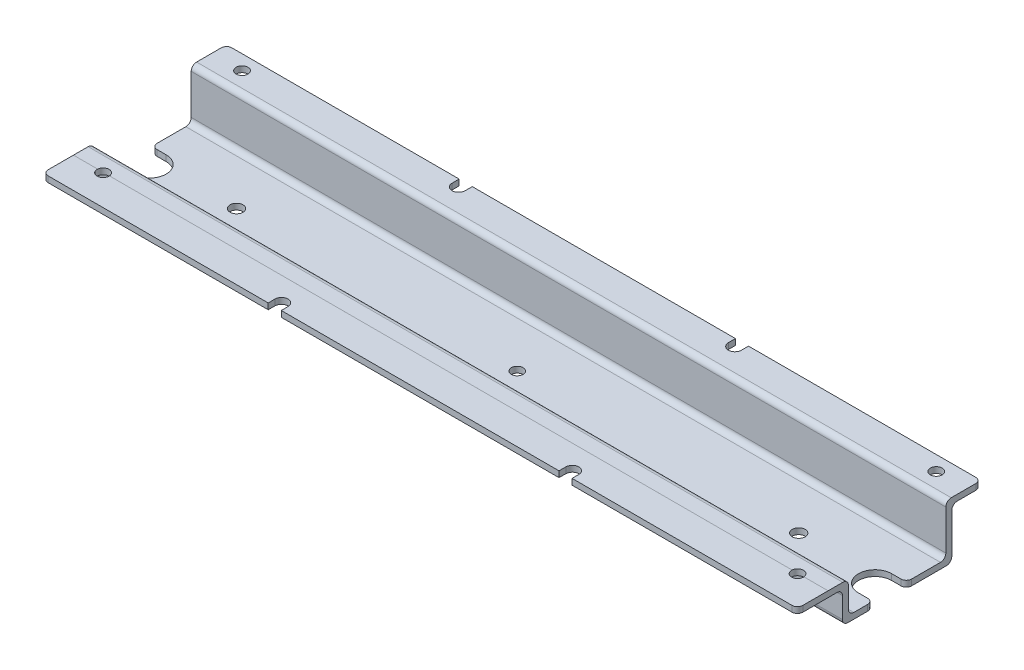
from build123d import *

# Parameters (mm, degrees)
BOSS_EXTRUDE1_DEPTH     = 202
FILLET1_R               = 1.44
FILLET2_R               = 1.44
SKETCH2_R               = 1.59
SKETCH2_R_2             = 1.735
SKETCH2_R_3             = 1.57
CUT_EXTRUDE1_DEPTH      = 6.1
CUT_EXTRUDE1_DEPTH_BACK = 11.04
FILLET3_R               = 1.44
BOSS_EXTRUDE2_DEPTH     = 202
CUT_EXTRUDE2_DEPTH      = 203
SKETCH5_R               = 1.59
CUT_EXTRUDE3_DEPTH      = 10
SKETCH6_R               = 1.59
BOSS_EXTRUDE3_DEPTH     = 1.59


with BuildPart() as part:
    # Sketch1 → Boss-Extrude1 (new body)
    with BuildSketch(Plane(origin=(0, 0, 0), x_dir=(0, 0, -1), z_dir=(1, 0, 0))):
        with BuildLine():
            Line((-15.04, 0), (15.04, 0))
            Line((15.04, 0), (15.19, 0))
            ThreePointArc((15.19, 0), (16.208233765, 0.421766235), (16.63, 1.44))
            Line((16.63, 1.44), (16.63, 12.11))
            ThreePointArc((16.63, 12.11), (17.051766235, 13.128233765), (18.07, 13.55))
            Line((18.07, 13.55), (24.5, 13.55))
            Line((24.5, 13.55), (24.5, 15.14))
            Line((24.5, 15.14), (16.48, 15.14))
            ThreePointArc((16.48, 15.14), (15.461766235, 14.718233765), (15.04, 13.7))
            Line((15.04, 13.7), (15.04, 3.03))
            ThreePointArc((15.04, 3.03), (14.618233765, 2.011766235), (13.6, 1.59))
            Line((13.6, 1.59), (-13.6, 1.59))
            ThreePointArc((-13.6, 1.59), (-14.618233765, 2.011766235), (-15.04, 3.03))
            Line((-15.04, 3.03), (-15.04, 8.6))
            ThreePointArc((-15.04, 8.6), (-15.461766235, 9.618233765), (-16.48, 10.04))
            Line((-16.48, 10.04), (-24.68, 10.04))
            Line((-24.68, 10.04), (-24.68, 8.45))
            Line((-24.68, 8.45), (-18.07, 8.45))
            ThreePointArc((-18.07, 8.45), (-17.051766235, 8.028233765), (-16.63, 7.01))
            Line((-16.63, 7.01), (-16.63, 1.44))
            ThreePointArc((-16.63, 1.44), (-16.208233765, 0.421766235), (-15.19, 0))
            Line((-15.19, 0), (-15.04, 0))
        make_face()
    extrude(amount=-BOSS_EXTRUDE1_DEPTH)

    # Fillet1
    fillet1_edges = [part.edges().sort_by_distance(p)[0] for p in [
        (0, 9.245, 24.68),
    ]]
    fillet(fillet1_edges, radius=FILLET1_R)

    # Fillet2
    fillet2_edges = [part.edges().sort_by_distance(p)[0] for p in [
        (-202, 14.345, -24.5),
        (0, 14.345, -24.5),
        (-202, 9.245, 24.68),
    ]]
    fillet(fillet2_edges, radius=FILLET2_R)

    # Sketch2 → Cut-Extrude1 (cut, two sides)
    with BuildSketch(Plane(origin=(0, 10.04, 0), x_dir=(1, 0, 0), z_dir=(0, 1, 0))) as cut_extrude1_sk:
        with Locations((-193.95, -20.6)):
            Circle(SKETCH2_R)
        with Locations((-8.05, -20.6)):
            Circle(SKETCH2_R)
        with Locations((-176.235, 1.415)):
            Circle(SKETCH2_R_2)
        with Locations((-25.765, 1.415)):
            Circle(SKETCH2_R_2)
        with Locations((-193.91, 20.563)):
            Circle(SKETCH2_R)
        with Locations((-101, 1.31)):
            Circle(SKETCH2_R_3)
        with Locations((-8.09, 20.563)):
            Circle(SKETCH2_R)
        with BuildLine():
            Line((0, 4.455), (0, -4.455))
            Line((0, -4.455), (-3.9, -4.455))
            ThreePointArc((-3.9, -4.455), (-8.355, 0), (-3.9, 4.455))
            Line((-3.9, 4.455), (0, 4.455))
        make_face()
        with BuildLine():
            Line((-141.669852281, -24.68), (-141.669852281, -22.87))
            ThreePointArc((-141.669852281, -22.87), (-139.919852281, -21.12), (-138.169852281, -22.87))
            Line((-138.169852281, -22.87), (-138.169852281, -24.68))
            Line((-138.169852281, -24.68), (-141.669852281, -24.68))
        make_face()
        with BuildLine():
            Line((-63.830147719, -22.87), (-63.830147719, -24.68))
            Line((-63.830147719, -24.68), (-60.330147719, -24.68))
            Line((-60.330147719, -24.68), (-60.330147719, -22.87))
            ThreePointArc((-60.330147719, -22.87), (-62.080147719, -21.12), (-63.830147719, -22.87))
        make_face()
        with BuildLine():
            Line((-139.73, 24.5), (-136.23, 24.5))
            Line((-136.23, 24.5), (-136.23, 22.6))
            ThreePointArc((-136.23, 22.6), (-137.98, 20.85), (-139.73, 22.6))
            Line((-139.73, 22.6), (-139.73, 24.5))
        make_face()
        with BuildLine():
            Line((-202, 4.455), (-202, -4.455))
            Line((-202, -4.455), (-198.1, -4.455))
            ThreePointArc((-198.1, -4.455), (-193.645, 0), (-198.1, 4.455))
            Line((-198.1, 4.455), (-202, 4.455))
        make_face()
        with BuildLine():
            Line((-62.27, 24.5), (-62.27, 22.6))
            ThreePointArc((-62.27, 22.6), (-64.02, 20.85), (-65.77, 22.6))
            Line((-65.77, 22.6), (-65.77, 24.5))
            Line((-65.77, 24.5), (-62.27, 24.5))
        make_face()
    extrude(amount=CUT_EXTRUDE1_DEPTH, mode=Mode.SUBTRACT)
    extrude(cut_extrude1_sk.sketch, amount=-CUT_EXTRUDE1_DEPTH_BACK, mode=Mode.SUBTRACT)

    # Fillet3
    fillet3_edges = [part.edges().sort_by_distance(p)[0] for p in [
        (-202, 0.795, 4.455),
        (-202, 0.795, -4.455),
        (0, 0.795, -4.455),
        (0, 0.795, 4.455),
    ]]
    fillet(fillet3_edges, radius=FILLET3_R)

    # Sketch3 → Boss-Extrude2 (add)
    with BuildSketch(Plane.ZY.offset(202)):
        with BuildLine():
            Line((15.04, 3.03), (15.04, 8.6))
            ThreePointArc((15.04, 8.6), (15.461766235, 9.618233765), (16.48, 10.04))
            Line((16.48, 10.04), (12.551925622, 10.038202595))
            ThreePointArc((12.551925622, 10.038202595), (11.487521511, 9.643353463), (11.04, 8.6))
            Line((11.04, 8.6), (11.04, 3.03))
            ThreePointArc((11.04, 3.03), (10.618233765, 2.011766235), (9.6, 1.59))
            Line((9.6, 1.59), (13.6, 1.59))
            ThreePointArc((13.6, 1.59), (14.618233765, 2.011766235), (15.04, 3.03))
        make_face()
    extrude(amount=-BOSS_EXTRUDE2_DEPTH)

    # Sketch4 → Cut-Extrude2 (cut, through all)
    with BuildSketch(Plane.ZY.offset(202)):
        with BuildLine():
            Line((16.63, 7.01), (16.63, 1.44))
            ThreePointArc((16.63, 1.44), (16.208233765, 0.421766235), (15.19, 0))
            Line((15.19, 0), (11.19, 0))
            ThreePointArc((11.19, 0), (12.208233765, 0.421766235), (12.63, 1.44))
            Line((12.63, 1.44), (12.63, 7.01))
            ThreePointArc((12.63, 7.01), (13.051766235, 8.028233765), (14.07, 8.45))
            Line((14.07, 8.45), (18.07, 8.45))
            ThreePointArc((18.07, 8.45), (17.051766235, 8.028233765), (16.63, 7.01))
        make_face()
    extrude(amount=-CUT_EXTRUDE2_DEPTH, mode=Mode.SUBTRACT)

    # Sketch5 → Cut-Extrude3 (cut)
    with BuildSketch(Plane(origin=(0, 10.04, 0), x_dir=(1, 0, 0), z_dir=(0, 1, 0))):
        with Locations((-193.95, -20.6)):
            Circle(SKETCH5_R)
        with Locations((-8.05, -20.6)):
            Circle(SKETCH5_R)
        with Locations((-193.95, -16.6)):
            Circle(SKETCH5_R)
        with Locations((-8.05, -16.6)):
            Circle(SKETCH5_R)
    extrude(amount=-CUT_EXTRUDE3_DEPTH, mode=Mode.SUBTRACT)

    # Sketch6 → Boss-Extrude3 (add)
    with BuildSketch(Plane(origin=(0, 10.04, 0), x_dir=(1, 0, 0), z_dir=(0, 1, 0))):
        with Locations((-193.95, -20.6)):
            Circle(SKETCH6_R)
        with Locations((-8.05, -20.6)):
            Circle(SKETCH6_R)
    extrude(amount=-BOSS_EXTRUDE3_DEPTH)


solid = part.part
